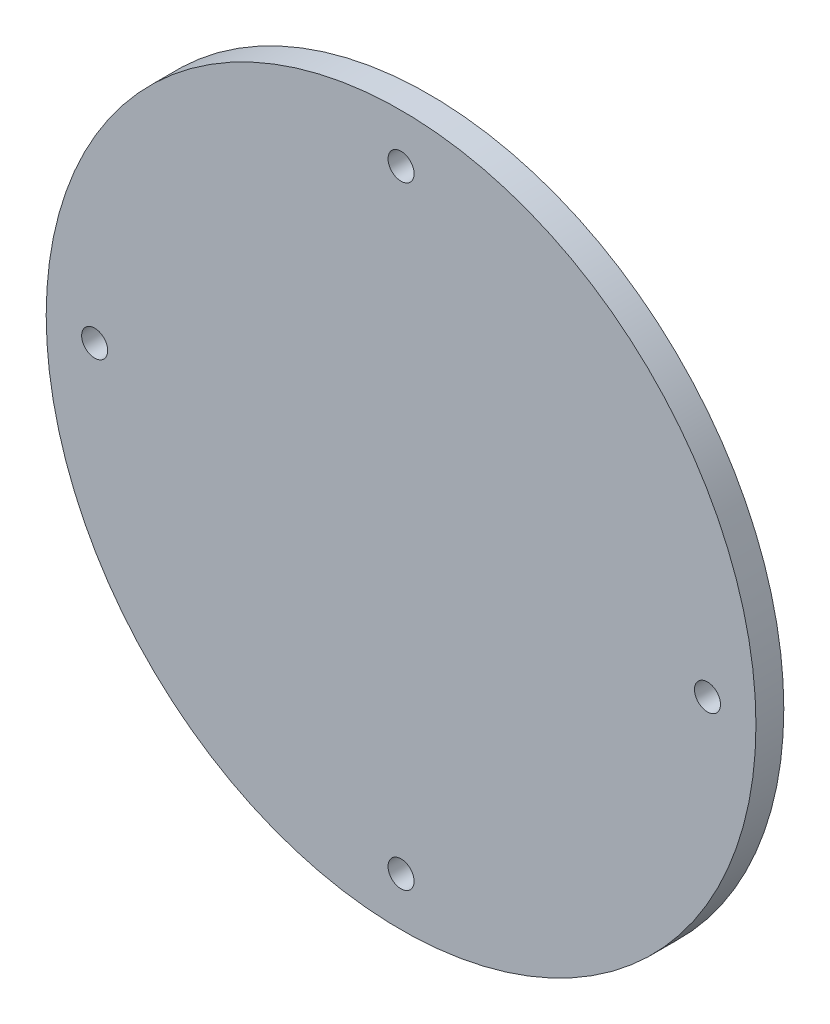
from build123d import *

# Parameters (mm, degrees)
SKETCH1_R           = 63.70040654
SKETCH1_R_2         = 2.335681573
BOSS_EXTRUDE1_DEPTH = 5


with BuildPart() as part:
    # Sketch1 → Boss-Extrude1 (new body)
    with BuildSketch(Plane.XY):
        Circle(SKETCH1_R)
        with Locations((0, 55)):
            Circle(SKETCH1_R_2, mode=Mode.SUBTRACT)
        with Locations((55, 0)):
            Circle(SKETCH1_R_2, mode=Mode.SUBTRACT)
        with Locations((0, -55)):
            Circle(SKETCH1_R_2, mode=Mode.SUBTRACT)
        with Locations((-55, 0)):
            Circle(SKETCH1_R_2, mode=Mode.SUBTRACT)
    extrude(amount=BOSS_EXTRUDE1_DEPTH)


solid = part.part
